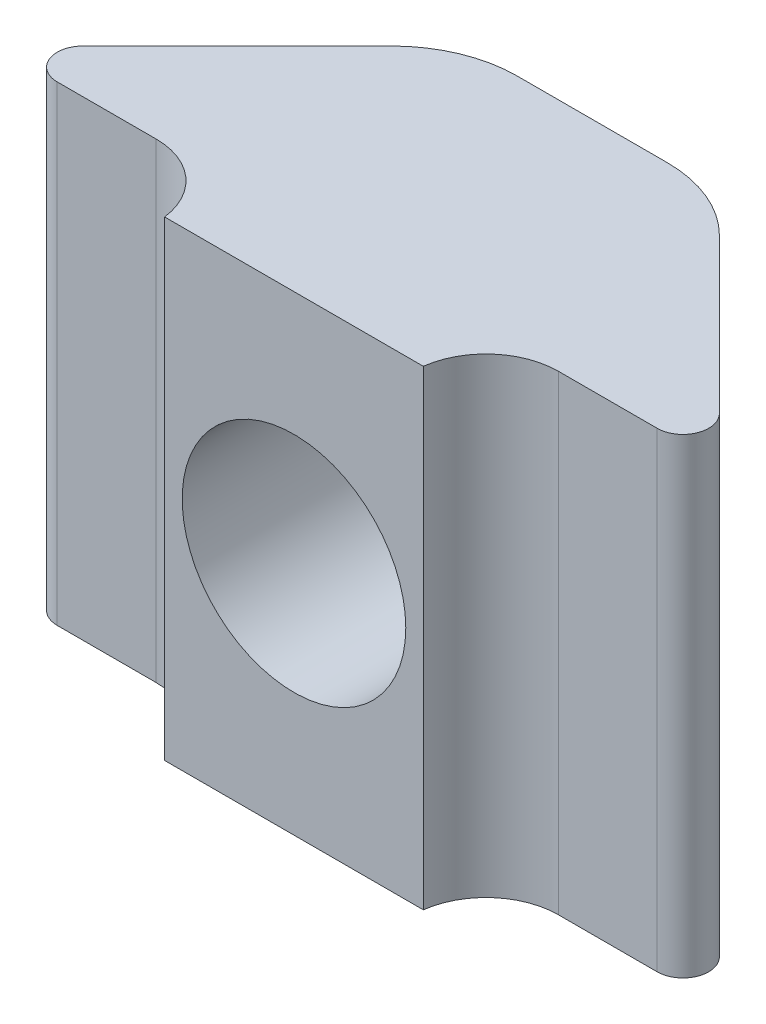
from build123d import *

# Parameters (mm, degrees)
BOSS_EXTRUDE1_DEPTH = 10.16
SKETCH2_R           = 2.413
CUT_EXTRUDE1_DEPTH  = 7.4393


with BuildPart() as part:
    # Sketch1 → Boss-Extrude1 (new body)
    with BuildSketch(Plane(origin=(0, 0, 0), x_dir=(1, 0, 0), z_dir=(0, 1, 0))):
        with BuildLine():
            Line((-4.3434, -5.2744), (-6.474794456, -5.2744))
            ThreePointArc((-6.474794456, -5.2744), (-6.988471476, -4.931171988), (-6.867945826, -4.32524863))
            Line((-6.867945826, -4.32524863), (-3.537902285, -0.995205089))
            ThreePointArc((-3.537902285, -0.995205089), (-2.657092893, -0.406667069), (-1.618107374, -0.2))
            Line((-1.618107374, -0.2), (1.618107374, -0.2))
            ThreePointArc((1.618107374, -0.2), (2.657092893, -0.406667069), (3.537902285, -0.995205089))
            Line((3.537902285, -0.995205089), (6.867945826, -4.32524863))
            ThreePointArc((6.867945826, -4.32524863), (6.988471476, -4.931171988), (6.474794456, -5.2744))
            Line((6.474794456, -5.2744), (4.343399971, -5.2744))
            ThreePointArc((4.343399971, -5.2744), (3.309975564, -5.66416341), (2.791332959, -6.6393))
            Line((2.791332959, -6.6393), (-2.791332988, -6.6393))
            ThreePointArc((-2.791332988, -6.6393), (-3.309975593, -5.66416341), (-4.3434, -5.2744))
        make_face()
    extrude(amount=BOSS_EXTRUDE1_DEPTH)

    # Sketch2 → Cut-Extrude1 (cut, through all)
    with BuildSketch(Plane.XY.offset(6.6393)):
        with Locations((-1.4e-08, 5.08)):
            Circle(SKETCH2_R)
    extrude(amount=-CUT_EXTRUDE1_DEPTH, mode=Mode.SUBTRACT)


solid = part.part
